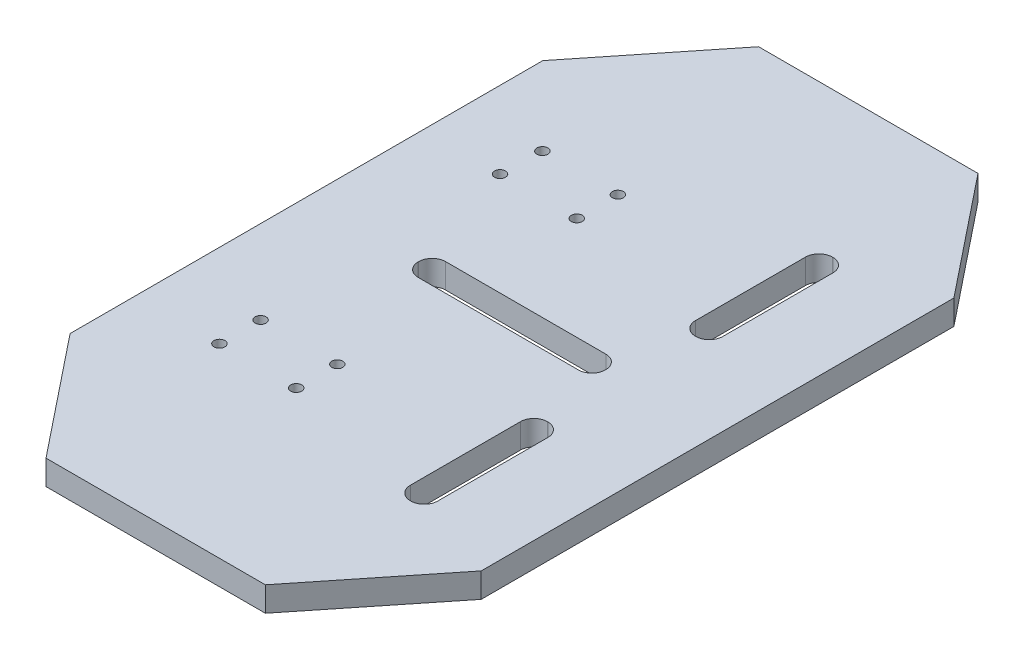
from build123d import *

# Parameters (mm, degrees)
BOSS_EXTRUDE1_DEPTH = 4.5
CUT_EXTRUDE2_DEPTH  = 10
SKETCH7_R           = 1
CUT_EXTRUDE3_DEPTH  = 5
SKETCH11_R          = 2
SKETCH11_R_2        = 1
CUT_EXTRUDE4_DEPTH  = 1.65


with BuildPart() as part:
    # Sketch1 → Boss-Extrude1 (new body)
    with BuildSketch(Plane(origin=(0, 0, 0), x_dir=(1, 0, 0), z_dir=(0, 1, 0))):
        Polygon((-37.5, -43.117707706), (-20.011895516, -65), (20.011895516, -65), (37.5, -43.117707706), (37.5, 43.117707706), (20.011895516, 65), (-20.011895516, 65), (-37.5, 43.117707706), align=None)
    extrude(amount=BOSS_EXTRUDE1_DEPTH)

    # Sketch5 → Cut-Extrude2 (cut)
    with BuildSketch(Plane(origin=(0, 4.5, 0), x_dir=(1, 0, 0), z_dir=(0, 1, 0))):
        with BuildLine():
            Line((-14.620176413, -2.5), (14.620176413, -2.5))
            ThreePointArc((14.620176413, -2.5), (16.352588027, -1.782411614), (17.070176413, -0.05))
            Line((17.070176413, -0.05), (17.070176413, 0.05))
            ThreePointArc((17.070176413, 0.05), (16.352588027, 1.782411614), (14.620176413, 2.5))
            Line((14.620176413, 2.5), (-14.620176413, 2.5))
            ThreePointArc((-14.620176413, 2.5), (-16.352588027, 1.782411614), (-17.070176413, 0.05))
            Line((-17.070176413, 0.05), (-17.070176413, -0.05))
            ThreePointArc((-17.070176413, -0.05), (-16.352588027, -1.782411614), (-14.620176413, -2.5))
        make_face()
        with BuildLine():
            Line((19.95, -38.5), (20.05, -38.5))
            ThreePointArc((20.05, -38.5), (21.782411614, -37.782411614), (22.5, -36.05))
            Line((22.5, -36.05), (22.5, -15.95))
            ThreePointArc((22.5, -15.95), (21.782411614, -14.217588386), (20.05, -13.5))
            Line((20.05, -13.5), (19.95, -13.5))
            ThreePointArc((19.95, -13.5), (18.217588386, -14.217588386), (17.5, -15.95))
            Line((17.5, -15.95), (17.5, -36.05))
            ThreePointArc((17.5, -36.05), (18.217588386, -37.782411614), (19.95, -38.5))
        make_face()
        with BuildLine():
            Line((19.95, 13.5), (20.05, 13.5))
            ThreePointArc((20.05, 13.5), (21.782411614, 14.217588386), (22.5, 15.95))
            Line((22.5, 15.95), (22.5, 36.05))
            ThreePointArc((22.5, 36.05), (21.782411614, 37.782411614), (20.05, 38.5))
            Line((20.05, 38.5), (19.95, 38.5))
            ThreePointArc((19.95, 38.5), (18.217588386, 37.782411614), (17.5, 36.05))
            Line((17.5, 36.05), (17.5, 15.95))
            ThreePointArc((17.5, 15.95), (18.217588386, 14.217588386), (19.95, 13.5))
        make_face()
    extrude(amount=-CUT_EXTRUDE2_DEPTH, mode=Mode.SUBTRACT)

    # Sketch7 → Cut-Extrude3 (cut)
    with BuildSketch(Plane(origin=(0, 4.5, 0), x_dir=(1, 0, 0), z_dir=(0, 1, 0))):
        with Locations((-9.476, 21.29)):
            Circle(SKETCH7_R)
        with Locations((-23.476, 21.29)):
            Circle(SKETCH7_R)
        with Locations((-23.24360758, 28.79)):
            Circle(SKETCH7_R)
        with Locations((-22.27, -23.6)):
            Circle(SKETCH7_R)
        with Locations((-22.27, -31.1)):
            Circle(SKETCH7_R)
        with Locations((-8.27, -31.1)):
            Circle(SKETCH7_R)
        with Locations((-8.27, -23.6)):
            Circle(SKETCH7_R)
        with Locations((-9.476, 28.79)):
            Circle(SKETCH7_R)
    extrude(amount=-CUT_EXTRUDE3_DEPTH, mode=Mode.SUBTRACT)

    # Sketch11 → Cut-Extrude4 (cut)
    with BuildSketch(Plane.XZ):
        with Locations((-8.27, 23.6)):
            Circle(SKETCH11_R)
        with Locations((-8.27, 23.6)):
            Circle(SKETCH11_R_2, mode=Mode.SUBTRACT)
        with Locations((-22.27, 23.6)):
            Circle(SKETCH11_R)
        with Locations((-22.27, 23.6)):
            Circle(SKETCH11_R_2, mode=Mode.SUBTRACT)
        with Locations((-9.476, -21.29)):
            Circle(SKETCH11_R)
        with Locations((-9.476, -21.29)):
            Circle(SKETCH11_R_2, mode=Mode.SUBTRACT)
        with Locations((-9.476, -28.79)):
            Circle(SKETCH11_R)
        with Locations((-9.476, -28.79)):
            Circle(SKETCH11_R_2, mode=Mode.SUBTRACT)
        with Locations((-8.27, 31.1)):
            Circle(SKETCH11_R)
        with Locations((-22.27, 31.1)):
            Circle(SKETCH11_R)
        with Locations((-23.24360758, -28.79)):
            Circle(SKETCH11_R)
        with Locations((-23.476, -21.29)):
            Circle(SKETCH11_R)
    extrude(amount=-CUT_EXTRUDE4_DEPTH, mode=Mode.SUBTRACT)


solid = part.part
